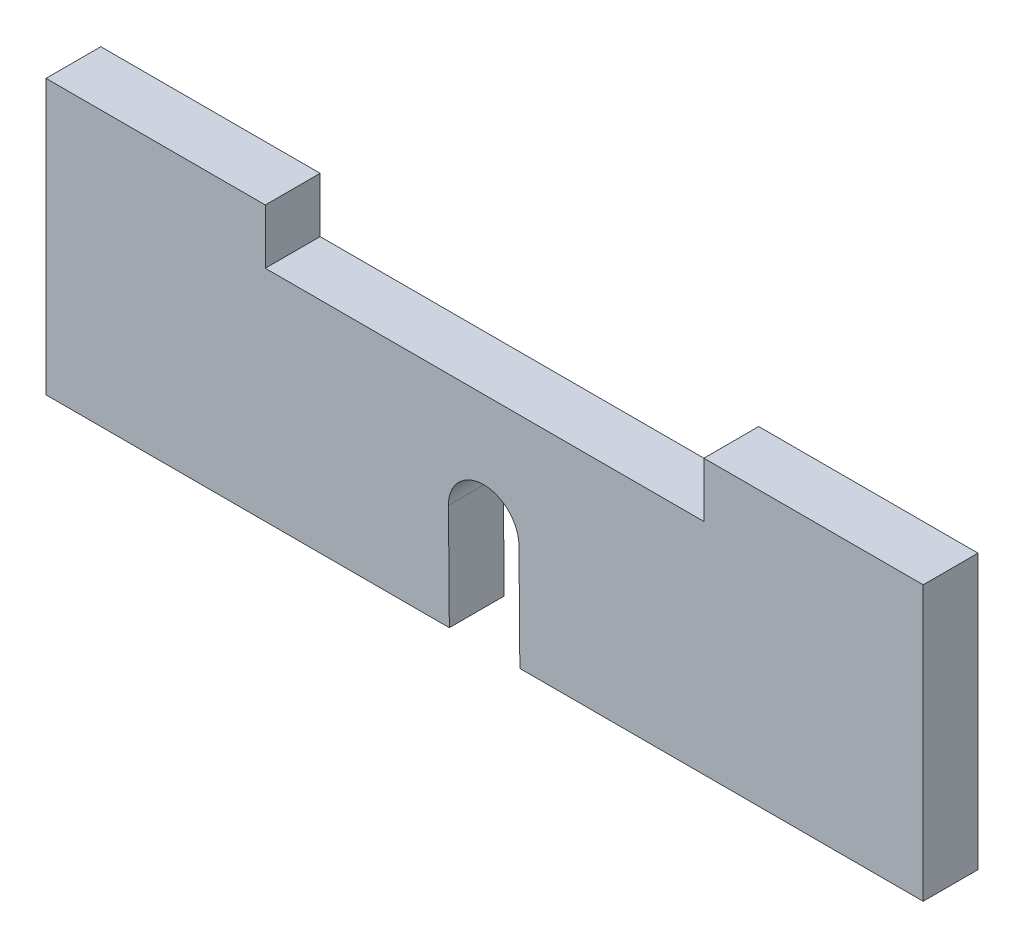
from build123d import *

# Parameters (mm, degrees)
SKETCH1_W       = 50.8
SKETCH1_H       = 12.7
EXTRUDE1_DEPTH  = 3.175
SKETCH3_W       = 12.7
SKETCH3_H       = 3.175
EXTRUDE3_DEPTH  = 3.175
LPATTERN1_COUNT = 2
LPATTERN1_PITCH = 38.1
EXTRUDE4_DEPTH  = 4.175


with BuildPart() as part:
    # Sketch1 → Extrude1 (new body)
    with BuildSketch(Plane.XY):
        with Locations((25.4, 6.35)):
            Rectangle(SKETCH1_W, SKETCH1_H)
    extrude(amount=EXTRUDE1_DEPTH)

    # Sketch3 → Extrude3 (add)
    with BuildSketch(Plane(origin=(0, 12.7, 0), x_dir=(1, 0, 0), z_dir=(0, 1, 0))):
        with Locations((6.35, -1.5875)):
            Rectangle(SKETCH3_W, SKETCH3_H)
    extrude3 = extrude(amount=EXTRUDE3_DEPTH)

    # LPattern1: Extrude3 ×2
    with Locations(*[(i * LPATTERN1_PITCH, 0, 0) for i in range(1, LPATTERN1_COUNT)]):
        add(extrude3)

    # Sketch4 → Extrude4 (cut, through all)
    with BuildSketch(Plane.XY.offset(3.175)):
        with BuildLine():
            Line((27.391652548, 6.144928853), (27.441911715, 0.016746365))
            ThreePointArc((27.441911715, 0.016746365), (25.416746365, -2.041911715), (23.358088285, -0.016746365))
            Line((23.358088285, -0.016746365), (23.307829118, 6.111436122))
            ThreePointArc((23.307829118, 6.111436122), (25.332994468, 8.170094203), (27.391652548, 6.144928853))
        make_face()
    extrude(amount=-EXTRUDE4_DEPTH, mode=Mode.SUBTRACT)


solid = part.part
